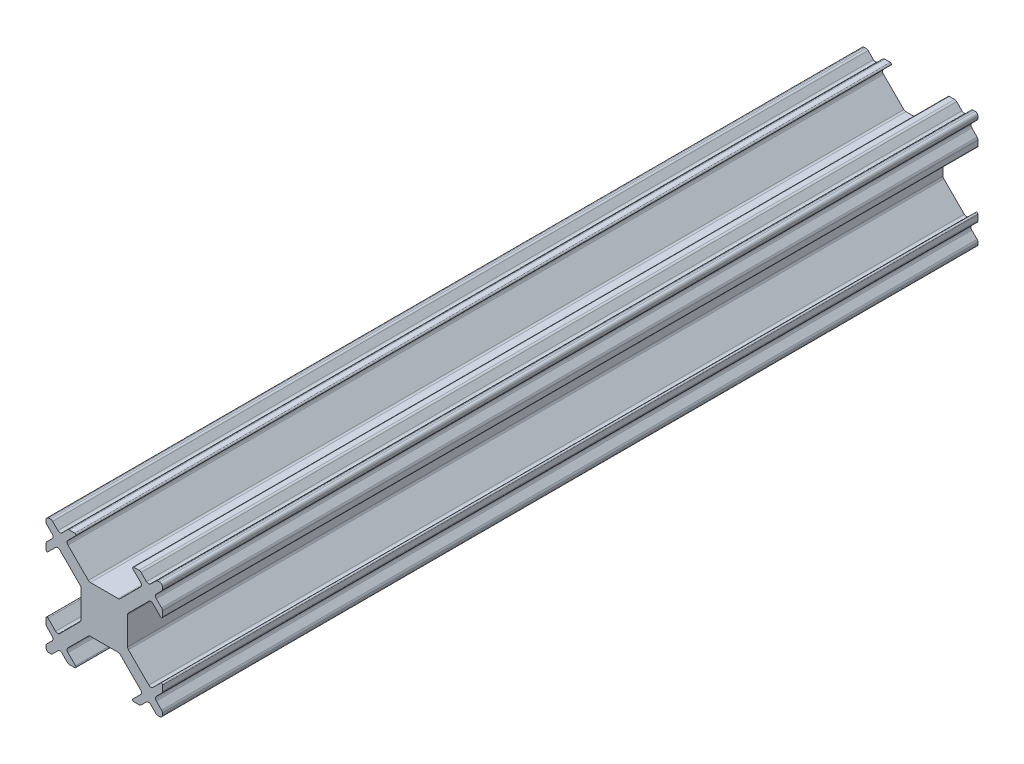
from build123d import *

# Parameters (mm, degrees)
BOSS_EXTRUDE1_DEPTH = 70


with BuildPart() as part:
    # Sketch1 → Boss-Extrude1 (new body)
    with BuildSketch(Plane.XY):
        with BuildLine():
            Line((-26.434620061, 28.496491655), (-25.979594809, 28.951516907))
            ThreePointArc((-25.979594809, 28.951516907), (-25.906371503, 29.128293603), (-25.979594808, 29.305070299))
            Line((-25.979594808, 29.305070299), (-26.43462006, 29.760095551))
            ThreePointArc((-26.43462006, 29.760095551), (-26.488813248, 29.841201388), (-26.507843365, 29.936872247))
            Line((-26.507843365, 29.936872247), (-26.507843365, 30.078293605))
            ThreePointArc((-26.507843365, 30.078293605), (-26.43462006, 30.255070299), (-26.257843366, 30.328293604))
            Line((-26.257843366, 30.328293604), (-26.11642201, 30.328293604))
            ThreePointArc((-26.11642201, 30.328293604), (-26.020751153, 30.309263487), (-25.939645316, 30.255070299))
            Line((-25.939645316, 30.255070299), (-25.484620061, 29.800045045))
            ThreePointArc((-25.484620061, 29.800045045), (-25.307843366, 29.72682174), (-25.131066671, 29.800045045))
            Line((-25.131066671, 29.800045045), (-24.676041418, 30.255070298))
            ThreePointArc((-24.676041418, 30.255070298), (-24.594935581, 30.309263487), (-24.499264722, 30.328293604))
            Line((-24.499264722, 30.328293604), (-24.042157942, 30.328293604))
            ThreePointArc((-24.042157942, 30.328293604), (-23.949769989, 30.266561947), (-23.971447265, 30.157582926))
            Line((-23.971447265, 30.157582926), (-24.623959891, 29.505070299))
            ThreePointArc((-24.623959891, 29.505070299), (-24.697183196, 29.328293604), (-24.623959891, 29.15151691))
            Line((-24.623959891, 29.15151691), (-22.873959891, 27.401516909))
            ThreePointArc((-22.873959891, 27.401516909), (-22.792854054, 27.347323722), (-22.697183196, 27.328293605))
            Line((-22.697183196, 27.328293605), (-20.318503539, 27.328293605))
            ThreePointArc((-20.318503539, 27.328293605), (-20.222832681, 27.347323722), (-20.141726844, 27.401516909))
            Line((-20.141726844, 27.401516909), (-18.391726844, 29.15151691))
            ThreePointArc((-18.391726844, 29.15151691), (-18.318503539, 29.328293604), (-18.391726844, 29.505070299))
            Line((-18.391726844, 29.505070299), (-19.04423947, 30.157582926))
            ThreePointArc((-19.04423947, 30.157582926), (-19.065916745, 30.266561947), (-18.973528793, 30.328293604))
            Line((-18.973528793, 30.328293604), (-18.516422013, 30.328293604))
            ThreePointArc((-18.516422013, 30.328293604), (-18.420751155, 30.309263487), (-18.339645319, 30.2550703))
            Line((-18.339645319, 30.2550703), (-17.884620064, 29.800045045))
            ThreePointArc((-17.884620064, 29.800045045), (-17.707843369, 29.72682174), (-17.531066674, 29.800045045))
            Line((-17.531066674, 29.800045045), (-17.07604142, 30.2550703))
            ThreePointArc((-17.07604142, 30.2550703), (-16.994935583, 30.309263487), (-16.899264725, 30.328293604))
            Line((-16.899264725, 30.328293604), (-16.75784337, 30.328293604))
            ThreePointArc((-16.75784337, 30.328293604), (-16.581066675, 30.255070299), (-16.507843371, 30.078293605))
            Line((-16.507843371, 30.078293605), (-16.507843371, 29.936872247))
            ThreePointArc((-16.507843371, 29.936872247), (-16.526873488, 29.841201389), (-16.581066675, 29.760095552))
            Line((-16.581066675, 29.760095552), (-17.036091927, 29.3050703))
            ThreePointArc((-17.036091927, 29.3050703), (-17.109315232, 29.128293603), (-17.036091926, 28.951516907))
            Line((-17.036091926, 28.951516907), (-16.581066674, 28.496491655))
            ThreePointArc((-16.581066674, 28.496491655), (-16.526873486, 28.415385818), (-16.507843369, 28.31971496))
            Line((-16.507843369, 28.31971496), (-16.507843369, 27.862608178))
            ThreePointArc((-16.507843369, 27.862608178), (-16.569575025, 27.770220231), (-16.678554041, 27.791897499))
            Line((-16.678554041, 27.791897499), (-17.331066668, 28.444410126))
            ThreePointArc((-17.331066668, 28.444410126), (-17.507843364, 28.517633431), (-17.68462006, 28.444410125))
            Line((-17.68462006, 28.444410125), (-19.434620061, 26.694410125))
            ThreePointArc((-19.434620061, 26.694410125), (-19.488813248, 26.613304288), (-19.507843364, 26.51763343))
            Line((-19.507843364, 26.51763343), (-19.507843364, 24.138953775))
            ThreePointArc((-19.507843364, 24.138953775), (-19.488813247, 24.043282917), (-19.434620059, 23.962177079))
            Line((-19.434620059, 23.962177079), (-17.684620059, 22.212177079))
            ThreePointArc((-17.684620059, 22.212177079), (-17.507843363, 22.138953773), (-17.331066666, 22.212177077))
            Line((-17.331066666, 22.212177077), (-16.67855404, 22.864689704))
            ThreePointArc((-16.67855404, 22.864689704), (-16.569575019, 22.886366979), (-16.507843363, 22.793979027))
            Line((-16.507843363, 22.793979027), (-16.507843363, 22.336872245))
            ThreePointArc((-16.507843363, 22.336872245), (-16.52687348, 22.241201387), (-16.581066668, 22.16009555))
            Line((-16.581066668, 22.16009555), (-17.036091921, 21.705070296))
            ThreePointArc((-17.036091921, 21.705070296), (-17.109315225, 21.528293601), (-17.036091921, 21.351516906))
            Line((-17.036091921, 21.351516906), (-16.581066669, 20.896491654))
            ThreePointArc((-16.581066669, 20.896491654), (-16.526873481, 20.815385817), (-16.507843364, 20.719714959))
            Line((-16.507843364, 20.719714959), (-16.507843364, 20.578293601))
            ThreePointArc((-16.507843364, 20.578293601), (-16.581066669, 20.401516906), (-16.757843364, 20.328293601))
            Line((-16.757843364, 20.328293601), (-16.89926472, 20.328293601))
            ThreePointArc((-16.89926472, 20.328293601), (-16.994935578, 20.347323718), (-17.076041415, 20.401516905))
            Line((-17.076041415, 20.401516905), (-17.53106667, 20.85654216))
            ThreePointArc((-17.53106667, 20.85654216), (-17.707843365, 20.929765464), (-17.88462006, 20.85654216))
            Line((-17.88462006, 20.85654216), (-18.339645314, 20.401516905))
            ThreePointArc((-18.339645314, 20.401516905), (-18.420751151, 20.347323718), (-18.516422009, 20.328293601))
            Line((-18.516422009, 20.328293601), (-18.973528789, 20.328293601))
            ThreePointArc((-18.973528789, 20.328293601), (-19.065916743, 20.390025258), (-19.044239468, 20.499004281))
            Line((-19.044239468, 20.499004281), (-18.391726841, 21.151516907))
            ThreePointArc((-18.391726841, 21.151516907), (-18.318503536, 21.328293602), (-18.391726841, 21.505070297))
            Line((-18.391726841, 21.505070297), (-20.141726841, 23.255070297))
            ThreePointArc((-20.141726841, 23.255070297), (-20.222832678, 23.309263485), (-20.318503536, 23.328293602))
            Line((-20.318503536, 23.328293602), (-22.697183193, 23.328293602))
            ThreePointArc((-22.697183193, 23.328293602), (-22.792854051, 23.309263485), (-22.873959889, 23.255070297))
            Line((-22.873959889, 23.255070297), (-24.623959889, 21.505070297))
            ThreePointArc((-24.623959889, 21.505070297), (-24.697183193, 21.328293602), (-24.623959889, 21.151516907))
            Line((-24.623959889, 21.151516907), (-23.971447262, 20.499004281))
            ThreePointArc((-23.971447262, 20.499004281), (-23.949769986, 20.390025258), (-24.042157941, 20.328293601))
            Line((-24.042157941, 20.328293601), (-24.49926472, 20.328293601))
            ThreePointArc((-24.49926472, 20.328293601), (-24.594935579, 20.347323718), (-24.676041417, 20.401516907))
            Line((-24.676041417, 20.401516907), (-25.131066671, 20.85654216))
            ThreePointArc((-25.131066671, 20.85654216), (-25.307843365, 20.929765464), (-25.48462006, 20.85654216))
            Line((-25.48462006, 20.85654216), (-25.939645315, 20.401516906))
            ThreePointArc((-25.939645315, 20.401516906), (-26.020751152, 20.347323718), (-26.11642201, 20.328293601))
            Line((-26.11642201, 20.328293601), (-26.257843366, 20.328293601))
            ThreePointArc((-26.257843366, 20.328293601), (-26.434620061, 20.401516906), (-26.507843366, 20.578293601))
            Line((-26.507843366, 20.578293601), (-26.507843366, 20.719714959))
            ThreePointArc((-26.507843366, 20.719714959), (-26.488813249, 20.815385817), (-26.434620061, 20.896491655))
            Line((-26.434620061, 20.896491655), (-25.979594809, 21.351516907))
            ThreePointArc((-25.979594809, 21.351516907), (-25.906371505, 21.528293602), (-25.979594809, 21.705070297))
            Line((-25.979594809, 21.705070297), (-26.434620063, 22.16009555))
            ThreePointArc((-26.434620063, 22.16009555), (-26.48881325, 22.241201387), (-26.507843367, 22.336872245))
            Line((-26.507843367, 22.336872245), (-26.507843367, 22.793979027))
            ThreePointArc((-26.507843367, 22.793979027), (-26.446111711, 22.88636698), (-26.337132691, 22.864689705))
            Line((-26.337132691, 22.864689705), (-25.684620064, 22.212177078))
            ThreePointArc((-25.684620064, 22.212177078), (-25.507843369, 22.138953774), (-25.331066674, 22.212177078))
            Line((-25.331066674, 22.212177078), (-23.581066674, 23.962177078))
            ThreePointArc((-23.581066674, 23.962177078), (-23.526873485, 24.043282916), (-23.507843368, 24.138953775))
            Line((-23.507843368, 24.138953775), (-23.507843368, 26.51763343))
            ThreePointArc((-23.507843368, 26.51763343), (-23.526873484, 26.613304288), (-23.581066672, 26.694410125))
            Line((-23.581066672, 26.694410125), (-25.331066672, 28.444410125))
            ThreePointArc((-25.331066672, 28.444410125), (-25.507843367, 28.51763343), (-25.684620062, 28.444410125))
            Line((-25.684620062, 28.444410125), (-26.337132689, 27.791897498))
            ThreePointArc((-26.337132689, 27.791897498), (-26.44611171, 27.770220225), (-26.507843366, 27.862608178))
            Line((-26.507843366, 27.862608178), (-26.507843366, 28.31971496))
            ThreePointArc((-26.507843366, 28.31971496), (-26.488813249, 28.415385818), (-26.434620061, 28.496491655))
        make_face()
    extrude(amount=BOSS_EXTRUDE1_DEPTH)


solid = part.part
